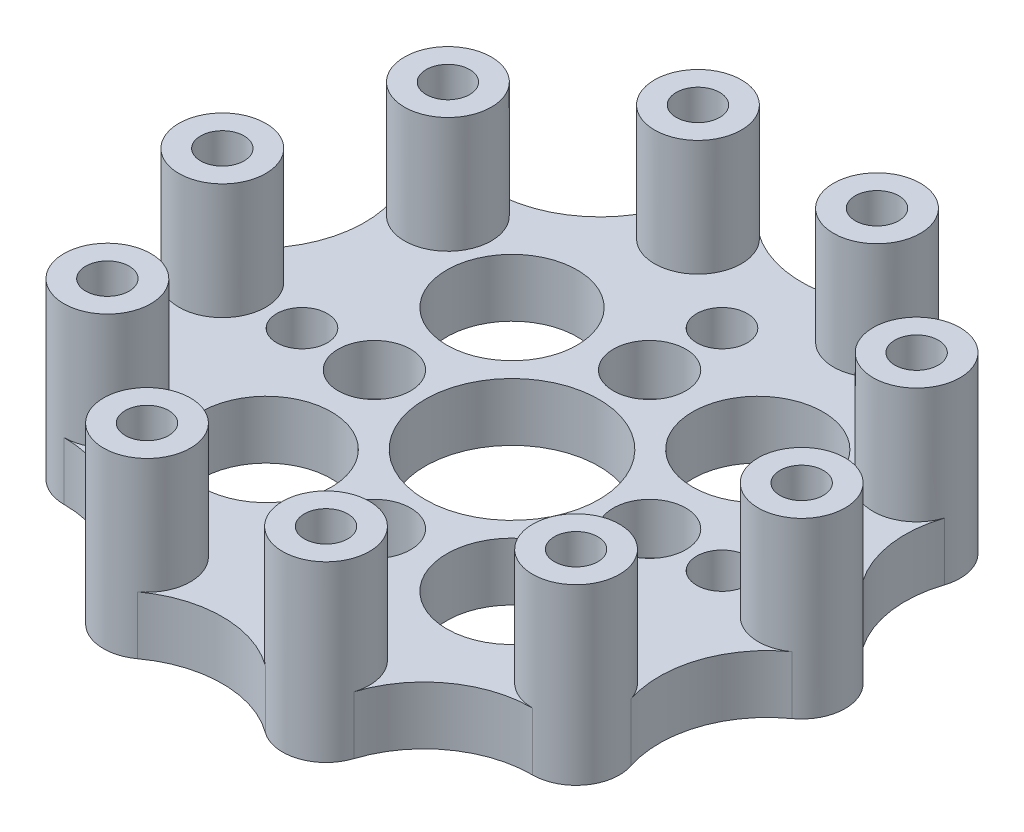
from build123d import *

# Parameters (mm, degrees)
SKETCH_1_R          = 1.5
SKETCH_1_R_2        = 6
SKETCH_1_R_3        = 4.5
SKETCH_1_R_4        = 1.75
EXTRUDE_1_DEPTH     = 4
SKETCH_2_R          = 2.5
CUT_EXTRUDE_1_DEPTH = 3.5
SKETCH_3_R          = 3
SKETCH_3_R_2        = 1.5
EXTRUDE_2_DEPTH     = 8
SKETCH_4_R          = 2.499477696
CUT_EXTRUDE_2_DEPTH = 4


with BuildPart() as part:
    # 草图1 → 凸台-拉伸1 (new body)
    with BuildSketch(Plane(origin=(0, 0, 0), x_dir=(1, 0, 0), z_dir=(0, 1, 0))):
        with BuildLine():
            ThreePointArc((21.75410191, -2.433747417), (23, 0), (21.75410191, 2.433747417))
            ThreePointArc((21.75410191, 2.433747417), (19.021130326, 6.180339887), (19.029958982, 10.81779726))
            ThreePointArc((19.029958982, 10.81779726), (18.607390871, 13.519060803), (16.168917304, 14.7556833))
            ThreePointArc((16.168917304, 14.7556833), (11.755705046, 16.180339887), (9.037018527, 19.937311066))
            ThreePointArc((9.037018527, 19.937311066), (7.107390871, 21.874299875), (4.407755848, 21.44144969))
            ThreePointArc((4.407755848, 21.44144969), (0, 20), (-4.407755848, 21.44144969))
            ThreePointArc((-4.407755848, 21.44144969), (-7.107390871, 21.874299875), (-9.037018527, 19.937311066))
            ThreePointArc((-9.037018527, 19.937311066), (-11.755705046, 16.180339887), (-16.168917304, 14.7556833))
            ThreePointArc((-16.168917304, 14.7556833), (-18.607390871, 13.519060803), (-19.029958982, 10.81779726))
            ThreePointArc((-19.029958982, 10.81779726), (-19.021130326, 6.180339887), (-21.75410191, 2.433747417))
            ThreePointArc((-21.75410191, 2.433747417), (-23, 0), (-21.75410191, -2.433747417))
            ThreePointArc((-21.75410191, -2.433747417), (-19.021130326, -6.180339887), (-19.029958982, -10.81779726))
            ThreePointArc((-19.029958982, -10.81779726), (-18.607390871, -13.519060803), (-16.168917304, -14.7556833))
            ThreePointArc((-16.168917304, -14.7556833), (-11.755705046, -16.180339887), (-9.037018527, -19.937311066))
            ThreePointArc((-9.037018527, -19.937311066), (-7.107390871, -21.874299875), (-4.407755848, -21.44144969))
            ThreePointArc((-4.407755848, -21.44144969), (0, -20), (4.407755848, -21.44144969))
            ThreePointArc((4.407755848, -21.44144969), (7.107390871, -21.874299875), (9.037018527, -19.937311066))
            ThreePointArc((9.037018527, -19.937311066), (11.755705046, -16.180339887), (16.168917304, -14.7556833))
            ThreePointArc((16.168917304, -14.7556833), (18.607390871, -13.519060803), (19.029958982, -10.81779726))
            ThreePointArc((19.029958982, -10.81779726), (19.021130326, -6.180339887), (21.75410191, -2.433747417))
        make_face()
        with Locations((20, 0)):
            Circle(SKETCH_1_R, mode=Mode.SUBTRACT)
        with Locations((16.180339887, -11.755705046)):
            Circle(SKETCH_1_R, mode=Mode.SUBTRACT)
        with Locations((6.180339887, -19.021130326)):
            Circle(SKETCH_1_R, mode=Mode.SUBTRACT)
        with Locations((-6.180339887, -19.021130326)):
            Circle(SKETCH_1_R, mode=Mode.SUBTRACT)
        with Locations((-16.180339887, -11.755705046)):
            Circle(SKETCH_1_R, mode=Mode.SUBTRACT)
        with Locations((-20, 0)):
            Circle(SKETCH_1_R, mode=Mode.SUBTRACT)
        with Locations((-16.180339887, 11.755705046)):
            Circle(SKETCH_1_R, mode=Mode.SUBTRACT)
        with Locations((-6.180339887, 19.021130326)):
            Circle(SKETCH_1_R, mode=Mode.SUBTRACT)
        with Locations((6.180339887, 19.021130326)):
            Circle(SKETCH_1_R, mode=Mode.SUBTRACT)
        with Locations((16.180339887, 11.755705046)):
            Circle(SKETCH_1_R, mode=Mode.SUBTRACT)
        with Locations((9.5, 0)):
            Circle(SKETCH_1_R, mode=Mode.SUBTRACT)
        with Locations((0, -9.5)):
            Circle(SKETCH_1_R, mode=Mode.SUBTRACT)
        with Locations((-9.5, 0)):
            Circle(SKETCH_1_R, mode=Mode.SUBTRACT)
        with Locations((0, 9.5)):
            Circle(SKETCH_1_R, mode=Mode.SUBTRACT)
        Circle(SKETCH_1_R_2, mode=Mode.SUBTRACT)
        with Locations((8.485281374, 8.485281374)):
            Circle(SKETCH_1_R_3, mode=Mode.SUBTRACT)
        with Locations((8.485281374, -8.485281374)):
            Circle(SKETCH_1_R_3, mode=Mode.SUBTRACT)
        with Locations((-8.485281374, -8.485281374)):
            Circle(SKETCH_1_R_3, mode=Mode.SUBTRACT)
        with Locations((-8.485281374, 8.485281374)):
            Circle(SKETCH_1_R_3, mode=Mode.SUBTRACT)
        with Locations((14.5, 0)):
            Circle(SKETCH_1_R_4, mode=Mode.SUBTRACT)
        with Locations((0, -14.5)):
            Circle(SKETCH_1_R_4, mode=Mode.SUBTRACT)
        with Locations((-14.5, 0)):
            Circle(SKETCH_1_R_4, mode=Mode.SUBTRACT)
        with Locations((0, 14.5)):
            Circle(SKETCH_1_R_4, mode=Mode.SUBTRACT)
    extrude(amount=EXTRUDE_1_DEPTH)

    # 草图2 → 切除-拉伸1 (cut)
    with BuildSketch(Plane(origin=(0, 4, 0), x_dir=(1, 0, 0), z_dir=(0, 1, 0))):
        with Locations((9.5, 0)):
            Circle(SKETCH_2_R)
        with Locations((0, -9.5)):
            Circle(SKETCH_2_R)
        with Locations((-9.5, 0)):
            Circle(SKETCH_2_R)
        with Locations((0, 9.5)):
            Circle(SKETCH_2_R)
    extrude(amount=-CUT_EXTRUDE_1_DEPTH, mode=Mode.SUBTRACT)

    # 草图3 → 凸台-拉伸2 (add)
    with BuildSketch(Plane(origin=(0, 4, 0), x_dir=(1, 0, 0), z_dir=(0, 1, 0))):
        with Locations((20, 0)):
            Circle(SKETCH_3_R)
        with Locations((20, 0)):
            Circle(SKETCH_3_R_2, mode=Mode.SUBTRACT)
        with Locations((16.180339887, -11.755705046)):
            Circle(SKETCH_3_R)
        with Locations((16.180339887, -11.755705046)):
            Circle(SKETCH_3_R_2, mode=Mode.SUBTRACT)
        with Locations((6.180339887, -19.021130326)):
            Circle(SKETCH_3_R)
        with Locations((6.180339887, -19.021130326)):
            Circle(SKETCH_3_R_2, mode=Mode.SUBTRACT)
        with Locations((-6.180339887, -19.021130326)):
            Circle(SKETCH_3_R)
        with Locations((-6.180339887, -19.021130326)):
            Circle(SKETCH_3_R_2, mode=Mode.SUBTRACT)
        with Locations((-16.180339887, -11.755705046)):
            Circle(SKETCH_3_R)
        with Locations((-16.180339887, -11.755705046)):
            Circle(SKETCH_3_R_2, mode=Mode.SUBTRACT)
        with Locations((-20, 0)):
            Circle(SKETCH_3_R)
        with Locations((-20, 0)):
            Circle(SKETCH_3_R_2, mode=Mode.SUBTRACT)
        with Locations((-16.180339887, 11.755705046)):
            Circle(SKETCH_3_R)
        with Locations((-16.180339887, 11.755705046)):
            Circle(SKETCH_3_R_2, mode=Mode.SUBTRACT)
        with Locations((-6.180339887, 19.021130326)):
            Circle(SKETCH_3_R)
        with Locations((-6.180339887, 19.021130326)):
            Circle(SKETCH_3_R_2, mode=Mode.SUBTRACT)
        with Locations((6.180339887, 19.021130326)):
            Circle(SKETCH_3_R)
        with Locations((6.180339887, 19.021130326)):
            Circle(SKETCH_3_R_2, mode=Mode.SUBTRACT)
        with Locations((16.180339887, 11.755705046)):
            Circle(SKETCH_3_R)
        with Locations((16.180339887, 11.755705046)):
            Circle(SKETCH_3_R_2, mode=Mode.SUBTRACT)
    extrude(amount=EXTRUDE_2_DEPTH)

    # 草图4 → 切除-拉伸2 (cut)
    with BuildSketch(Plane.XZ):
        with Locations((20, 0)):
            Circle(SKETCH_4_R)
        with Locations((16.180339887, -11.755705046)):
            Circle(SKETCH_4_R)
        with Locations((6.180339887, -19.021130326)):
            Circle(SKETCH_4_R)
        with Locations((-6.180339887, -19.021130326)):
            Circle(SKETCH_4_R)
        with Locations((-16.180339887, -11.755705046)):
            Circle(SKETCH_4_R)
        with Locations((-20, 0)):
            Circle(SKETCH_4_R)
        with Locations((-16.180339887, 11.755705046)):
            Circle(SKETCH_4_R)
        with Locations((-6.180339887, 19.021130326)):
            Circle(SKETCH_4_R)
        with Locations((6.180339887, 19.021130326)):
            Circle(SKETCH_4_R)
        with Locations((16.180339887, 11.755705046)):
            Circle(SKETCH_4_R)
    extrude(amount=-CUT_EXTRUDE_2_DEPTH, mode=Mode.SUBTRACT)


solid = part.part
